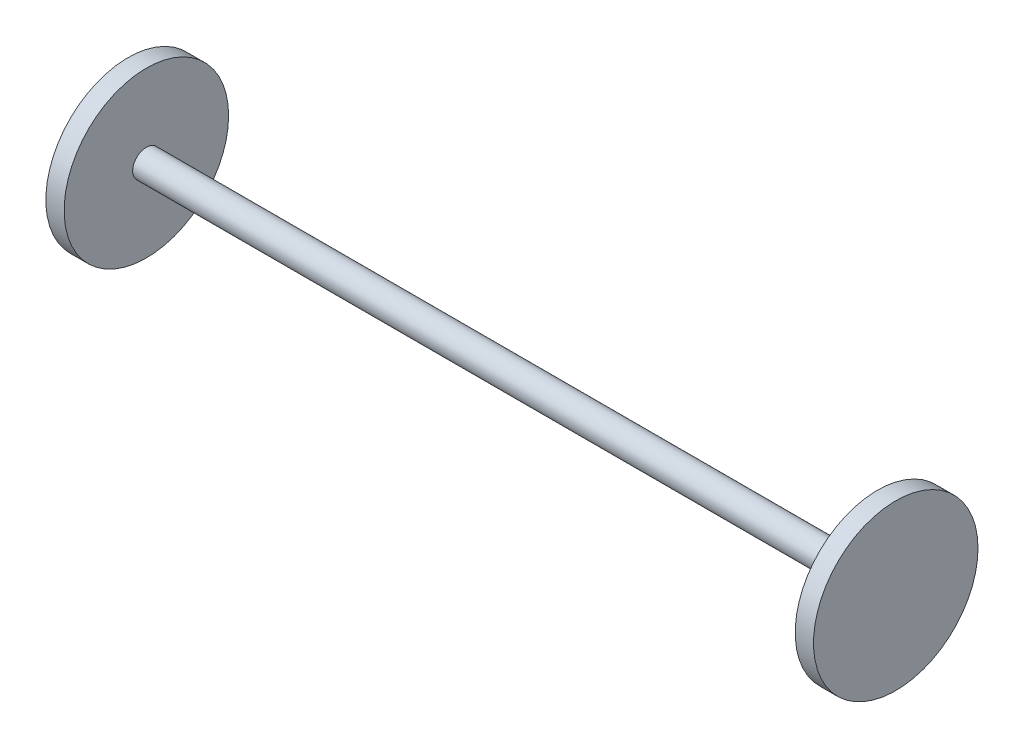
from build123d import *

# Parameters (mm, degrees)
SKETCH1_R           = 7.5
BOSS_EXTRUDE1_DEPTH = 200
SKETCH2_R           = 45
BOSS_EXTRUDE2_DEPTH = 10


with BuildPart() as part:
    # Sketch1 → Boss-Extrude1 (new body, symmetric)
    with BuildSketch(Plane(origin=(0, 0, 0), x_dir=(0, 0, -1), z_dir=(1, 0, 0))):
        Circle(SKETCH1_R)
    extrude(amount=BOSS_EXTRUDE1_DEPTH, both=True)

    # Sketch2 → Boss-Extrude2 (add)
    with BuildSketch(Plane(origin=(200, 0, 0), x_dir=(0, 0, -1), z_dir=(1, 0, 0))):
        Circle(SKETCH2_R)
    boss_extrude2 = extrude(amount=BOSS_EXTRUDE2_DEPTH)

    # Mirror1: Boss-Extrude2 across plane
    add(boss_extrude2.mirror(Plane(origin=(0, 0, 0), x_dir=(0, 0, 1), z_dir=(1, 0, 0))))


solid = part.part
